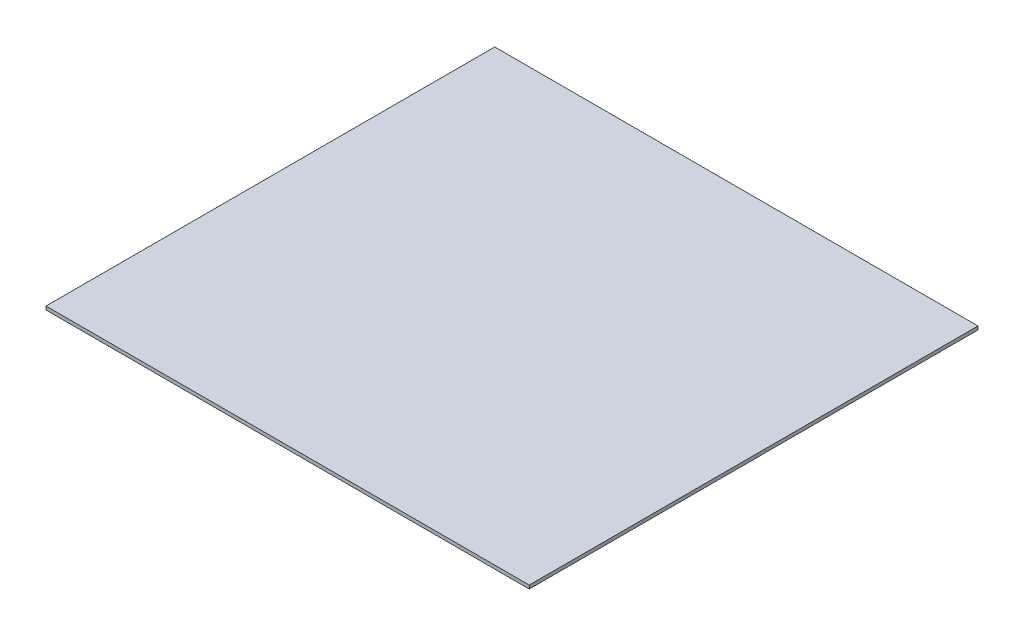
from build123d import *

# Parameters (mm, degrees)
SKETCH2_W           = 70
SKETCH2_H           = 65
BOSS_EXTRUDE1_DEPTH = 0.5


with BuildPart() as part:
    # Sketch2 → Boss-Extrude1 (new body)
    with BuildSketch(Plane(origin=(0, 0, 0), x_dir=(1, 0, 0), z_dir=(0, 1, 0))):
        with Locations((-1.395348837, -7.38372093)):
            Rectangle(SKETCH2_W, SKETCH2_H)
    extrude(amount=BOSS_EXTRUDE1_DEPTH)


solid = part.part
